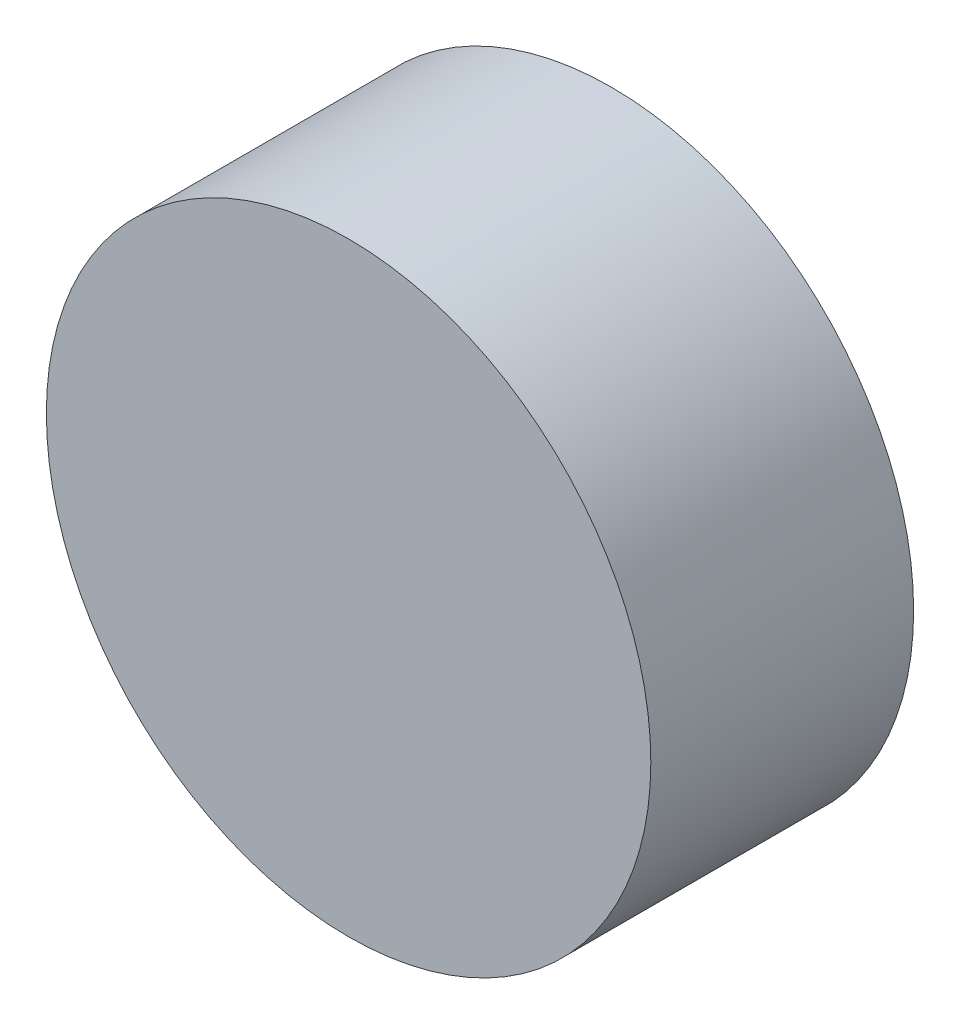
from build123d import *

# Parameters (mm, degrees)
SKETCH_1_R      = 5.75
EXTRUDE_1_DEPTH = 5


with BuildPart() as part:
    # 草圖1 → 填料-伸長1 (new body)
    with BuildSketch(Plane.XY):
        Circle(SKETCH_1_R)
    extrude(amount=EXTRUDE_1_DEPTH)


solid = part.part
